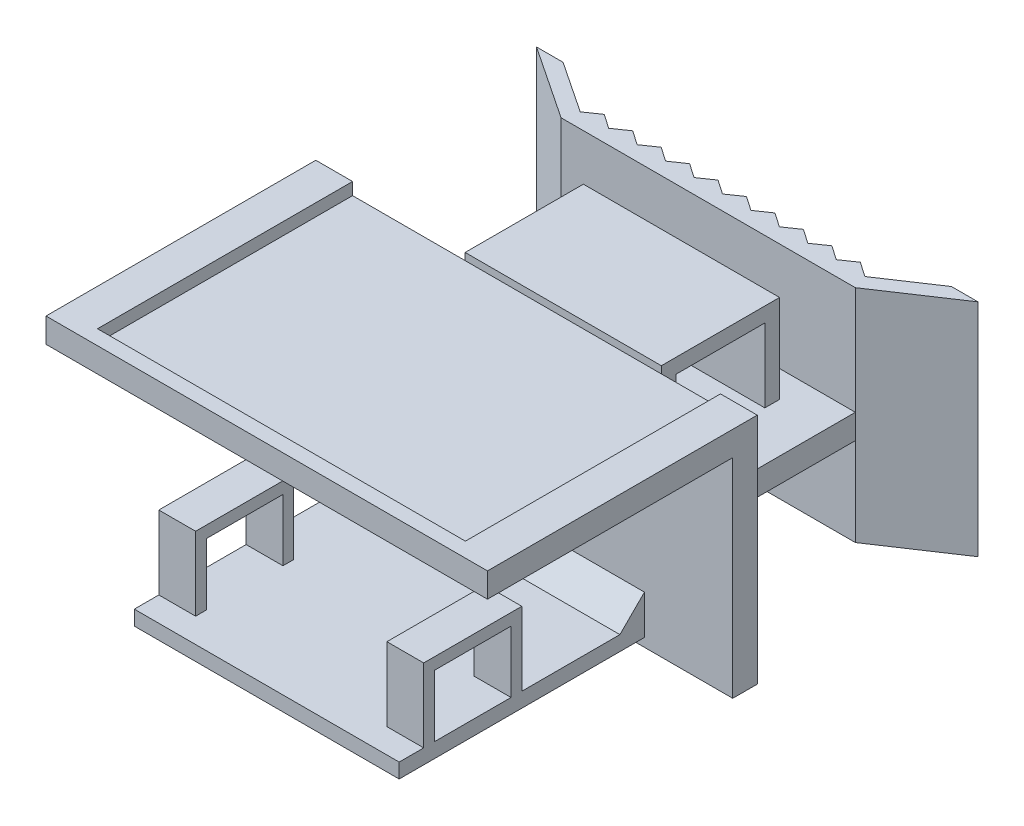
from build123d import *

# Parameters (mm, degrees)
CROQUIS1_W                          = 90
CROQUIS1_H                          = 50
SALIENTE_EXTRUIR1_DEPTH             = 5
CROQUIS4_W                          = 90
CROQUIS4_H                          = 5
SALIENTE_EXTRUIR2_DEPTH             = 49.5
CROQUIS5_W                          = 60
CROQUIS5_H                          = 5
SALIENTE_EXTRUIR3_DEPTH             = 35
CROQUIS11_W                         = 75
CROQUIS11_H                         = 80
CORTAR_EXTRUIR3_DEPTH               = 2.5
SALIENTE_EXTRUIR4_REACH             = 27
SALIENTE_EXTRUIR4_DIRECTION_2_REACH = 26.5
CROQUIS13_W                         = 90
CROQUIS13_H                         = 5
CORTAR_EXTRUIR4_DEPTH               = 1
CROQUIS15_W                         = 54
CROQUIS15_H                         = 3
SALIENTE_EXTRUIR5_DEPTH             = 50
CROQUIS18_W                         = 90
CROQUIS18_H                         = 5
CORTAR_EXTRUIR5_DEPTH               = 1
SALIENTE_EXTRUIR6_REACH             = 47
SALIENTE_EXTRUIR6_DIRECTION_2_REACH = 47
SALIENTE_EXTRUIR7_DEPTH             = 20
CROQUIS24_W                         = 20
CROQUIS24_H                         = 15
SALIENTE_EXTRUIR8_DEPTH             = 54
CROQUIS25_W                         = 15.6
CROQUIS25_H                         = 12.6
CORTAR_EXTRUIR6_DEPTH               = 54
CROQUIS26_W                         = 39
CROQUIS26_H                         = 15
CORTAR_EXTRUIR7_DEPTH               = 20


with BuildPart() as part:
    # Croquis1 → Saliente-Extruir1 (new body)
    with BuildSketch(Plane(origin=(0, 0, 0), x_dir=(1, 0, 0), z_dir=(0, 1, 0))):
        Rectangle(CROQUIS1_W, CROQUIS1_H)
    extrude(amount=SALIENTE_EXTRUIR1_DEPTH)

    # Croquis4 → Saliente-Extruir2 (add)
    with BuildSketch(Plane(origin=(0, 5, 0), x_dir=(1, 0, 0), z_dir=(0, 1, 0))):
        with Locations((0, 27.5)):
            Rectangle(CROQUIS4_W, CROQUIS4_H)
    extrude(amount=-SALIENTE_EXTRUIR2_DEPTH)

    # Croquis5 → Saliente-Extruir3 (add)
    with BuildSketch(Plane(origin=(0, 0, -30), x_dir=(-1, 0, 0), z_dir=(0, 0, -1))):
        with Locations((0, -22)):
            Rectangle(CROQUIS5_W, CROQUIS5_H)
    extrude(amount=SALIENTE_EXTRUIR3_DEPTH)

    # Croquis11 → Cortar-Extruir3 (cut)
    with BuildSketch(Plane(origin=(0, 5, 0), x_dir=(1, 0, 0), z_dir=(0, 1, 0))):
        with Locations((0, 18)):
            Rectangle(CROQUIS11_W, CROQUIS11_H)
    extrude(amount=-CORTAR_EXTRUIR3_DEPTH, mode=Mode.SUBTRACT)

    # Saliente-Extruir4: up to this face of the body (flat: up to its plane)
    saliente_extruir4_end = Plane(part.part.faces().sort_by_distance((0, -44.5, -27.5))[0])
    # Croquis12 → Saliente-Extruir4 (add, up to the picked face)
    with BuildSketch(Plane(origin=(0, -19.5, 0), x_dir=(1, 0, 0), z_dir=(0, 1, 0)), mode=Mode.PRIVATE) as saliente_extruir4_sk1:
        Polygon((-39.591673087, 75), (-45, 75), (-30, 65), (30, 65), (45, 75), (39.591673087, 75), (29.091673087, 68), (28.908326913, 68), (26.008326913, 70), (23.108326913, 68), (20.208326913, 70), (17.308326913, 68), (14.408326913, 70), (11.508326913, 68), (8.608326913, 70), (5.708326913, 68), (2.808326913, 70), (-0.091673087, 68), (-2.991673087, 70), (-5.891673087, 68), (-8.791673087, 70), (-11.691673087, 68), (-14.591673087, 70), (-17.491673087, 68), (-20.391673087, 70), (-23.291673087, 68), (-26.191673087, 70), (-29.091673087, 68), align=None)
    saliente_extruir4_tool1 = split(extrude(saliente_extruir4_sk1.sketch, amount=-SALIENTE_EXTRUIR4_REACH, mode=Mode.PRIVATE), bisect_by=saliente_extruir4_end, keep=Keep.BOTH, mode=Mode.PRIVATE)
    add(saliente_extruir4_tool1.solids().sort_by_distance((-27.127569, -19.5, -68.254549))[0])

    # Saliente-Extruir4 direction 2: up to this face of the body (flat: up to its plane)
    saliente_extruir4_direction_2_end = Plane(part.part.faces().sort_by_distance((0, 2.5, -4))[0])
    # Croquis12 → Saliente-Extruir4 direction 2 (add, up to the picked face)
    with BuildSketch(Plane(origin=(0, -19.5, 0), x_dir=(1, 0, 0), z_dir=(0, 1, 0)), mode=Mode.PRIVATE) as saliente_extruir4_direction_2_sk1:
        Polygon((-39.591673087, 75), (-45, 75), (-30, 65), (30, 65), (45, 75), (39.591673087, 75), (29.091673087, 68), (28.908326913, 68), (26.008326913, 70), (23.108326913, 68), (20.208326913, 70), (17.308326913, 68), (14.408326913, 70), (11.508326913, 68), (8.608326913, 70), (5.708326913, 68), (2.808326913, 70), (-0.091673087, 68), (-2.991673087, 70), (-5.891673087, 68), (-8.791673087, 70), (-11.691673087, 68), (-14.591673087, 70), (-17.491673087, 68), (-20.391673087, 70), (-23.291673087, 68), (-26.191673087, 70), (-29.091673087, 68), align=None)
    saliente_extruir4_direction_2_tool1 = split(extrude(saliente_extruir4_direction_2_sk1.sketch, amount=SALIENTE_EXTRUIR4_DIRECTION_2_REACH, mode=Mode.PRIVATE), bisect_by=saliente_extruir4_direction_2_end, keep=Keep.BOTH, mode=Mode.PRIVATE)
    add(saliente_extruir4_direction_2_tool1.solids().sort_by_distance((-27.127569, -19.5, -68.254549))[0])

    # Croquis13 → Cortar-Extruir4 (cut)
    with BuildSketch(Plane.XZ.offset(44.5)):
        with Locations((0, -27.5)):
            Rectangle(CROQUIS13_W, CROQUIS13_H)
        Polygon((-39.591673087, -75), (-29.091673087, -68), (-26.191673087, -70), (-23.291673087, -68), (-20.391673087, -70), (-17.491673087, -68), (-14.591673087, -70), (-11.691673087, -68), (-8.791673087, -70), (-5.891673087, -68), (-2.991673087, -70), (-0.091673087, -68), (2.808326913, -70), (5.708326913, -68), (8.608326913, -70), (11.508326913, -68), (14.408326913, -70), (17.308326913, -68), (20.208326913, -70), (23.108326913, -68), (26.008326913, -70), (28.908326913, -68), (29.091673087, -68), (39.591673087, -75), (45, -75), (30, -65), (-30, -65), (-45, -75), align=None)
    extrude(amount=-CORTAR_EXTRUIR4_DEPTH, mode=Mode.SUBTRACT)

    # Croquis15 → Saliente-Extruir5 (add)
    with BuildSketch(Plane.XY.offset(-25)):
        with Locations((0, -39.25)):
            Rectangle(CROQUIS15_W, CROQUIS15_H)
    extrude(amount=SALIENTE_EXTRUIR5_DEPTH)

    # Croquis18 → Cortar-Extruir5 (cut)
    with BuildSketch(Plane.XZ.offset(43.5)):
        with Locations((0, -27.5)):
            Rectangle(CROQUIS18_W, CROQUIS18_H)
        Polygon((-45, -75), (-39.591673087, -75), (-29.091673087, -68), (-26.191673087, -70), (-23.291673087, -68), (-20.391673087, -70), (-17.491673087, -68), (-14.591673087, -70), (-11.691673087, -68), (-8.791673087, -70), (-5.891673087, -68), (-2.991673087, -70), (-0.091673087, -68), (2.808326913, -70), (5.708326913, -68), (8.608326913, -70), (11.508326913, -68), (14.408326913, -70), (17.308326913, -68), (20.208326913, -70), (23.108326913, -68), (26.008326913, -70), (28.908326913, -68), (29.091673087, -68), (39.591673087, -75), (45, -75), (30, -65), (-30, -65), align=None)
    extrude(amount=-CORTAR_EXTRUIR5_DEPTH, mode=Mode.SUBTRACT)

    # Saliente-Extruir6: up to this face of the body (flat: up to its plane)
    saliente_extruir6_end = Plane(part.part.faces().sort_by_distance((-27, -39.25, 0))[0])
    # Croquis22 → Saliente-Extruir6 (add, up to the picked face)
    with BuildSketch(Plane(origin=(0, 0, 0), x_dir=(0, 0, -1), z_dir=(1, 0, 0)), mode=Mode.PRIVATE) as saliente_extruir6_sk1:
        Polygon((25, -37.75), (25, -32.75), (20, -37.75), align=None)
    saliente_extruir6_tool1 = split(extrude(saliente_extruir6_sk1.sketch, amount=-SALIENTE_EXTRUIR6_REACH, mode=Mode.PRIVATE), bisect_by=saliente_extruir6_end, keep=Keep.BOTH, mode=Mode.PRIVATE)
    add(saliente_extruir6_tool1.solids().sort_by_distance((0, -36.083333, -23.333333))[0])

    # Saliente-Extruir6 direction 2: up to this face of the body (flat: up to its plane)
    saliente_extruir6_direction_2_end = Plane(part.part.faces().sort_by_distance((27, -39.25, 0))[0])
    # Croquis22 → Saliente-Extruir6 direction 2 (add, up to the picked face)
    with BuildSketch(Plane(origin=(0, 0, 0), x_dir=(0, 0, -1), z_dir=(1, 0, 0)), mode=Mode.PRIVATE) as saliente_extruir6_direction_2_sk1:
        Polygon((25, -37.75), (25, -32.75), (20, -37.75), align=None)
    saliente_extruir6_direction_2_tool1 = split(extrude(saliente_extruir6_direction_2_sk1.sketch, amount=SALIENTE_EXTRUIR6_DIRECTION_2_REACH, mode=Mode.PRIVATE), bisect_by=saliente_extruir6_direction_2_end, keep=Keep.BOTH, mode=Mode.PRIVATE)
    add(saliente_extruir6_direction_2_tool1.solids().sort_by_distance((0, -36.083333, -23.333333))[0])

    # Croquis23 → Saliente-Extruir7 (add, symmetric)
    with BuildSketch(Plane(origin=(0, 0, 0), x_dir=(0, 0, -1), z_dir=(1, 0, 0))):
        Polygon((38.45, -4.5), (56.55, -4.5), (56.55, -19.5), (59.55, -19.5), (59.55, -1.5), (35.45, -1.5), (35.45, -19.5), (38.45, -19.5), align=None)
    extrude(amount=SALIENTE_EXTRUIR7_DEPTH, both=True)

    # Croquis24 → Saliente-Extruir8 (add)
    with BuildSketch(Plane.ZY.offset(27)):
        with Locations((10, -30.25)):
            Rectangle(CROQUIS24_W, CROQUIS24_H)
    extrude(amount=-SALIENTE_EXTRUIR8_DEPTH)

    # Croquis25 → Cortar-Extruir6 (cut)
    with BuildSketch(Plane.ZY.offset(27)):
        with Locations((10, -31.45)):
            Rectangle(CROQUIS25_W, CROQUIS25_H)
    extrude(amount=-CORTAR_EXTRUIR6_DEPTH, mode=Mode.SUBTRACT)

    # Croquis26 → Cortar-Extruir7 (cut)
    with BuildSketch(Plane.XY.offset(20)):
        with Locations((0, -30.25)):
            Rectangle(CROQUIS26_W, CROQUIS26_H)
    extrude(amount=-CORTAR_EXTRUIR7_DEPTH, mode=Mode.SUBTRACT)


solid = part.part
